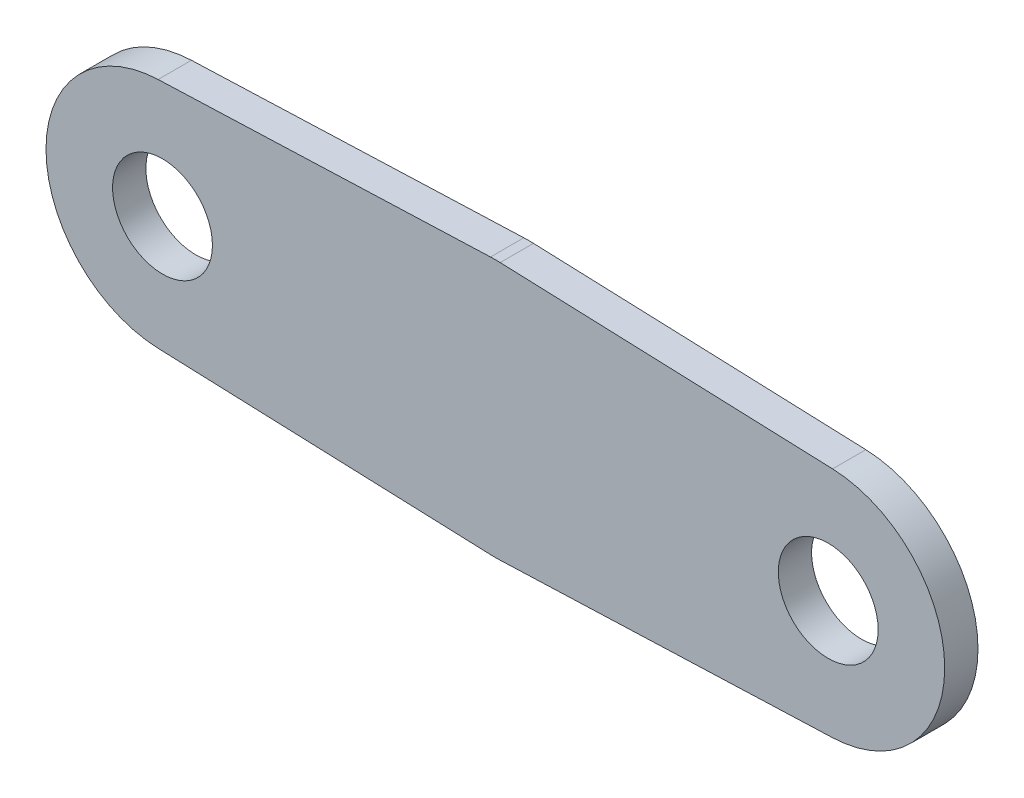
from build123d import *

# Parameters (mm, degrees)
SZKIC1_R                    = 3
DODANIE_WYCI_GNI_CIE1_DEPTH = 2


with BuildPart() as part:
    # Szkic1 → Dodanie-wyciągnięcie1 (new body)
    with BuildSketch(Plane.XY):
        with BuildLine():
            Line((-0.290625, 7.744548864), (-20.2625, 6.995076393))
            ThreePointArc((-20.2625, 6.995076393), (-27, 0), (-20.2625, -6.995076393))
            Line((-20.2625, -6.995076393), (-0.290625, -7.744548864))
            ThreePointArc((-0.290625, -7.744548864), (0, -7.75), (0.290625, -7.744548864))
            Line((0.290625, -7.744548864), (20.2625, -6.995076393))
            ThreePointArc((20.2625, -6.995076393), (27, 0), (20.2625, 6.995076393))
            Line((20.2625, 6.995076393), (0.290625, 7.744548864))
            ThreePointArc((0.290625, 7.744548864), (0, 7.75), (-0.290625, 7.744548864))
        make_face()
        with Locations((-20, 0)):
            Circle(SZKIC1_R, mode=Mode.SUBTRACT)
        with Locations((20, 0)):
            Circle(SZKIC1_R, mode=Mode.SUBTRACT)
    extrude(amount=DODANIE_WYCI_GNI_CIE1_DEPTH)


solid = part.part
